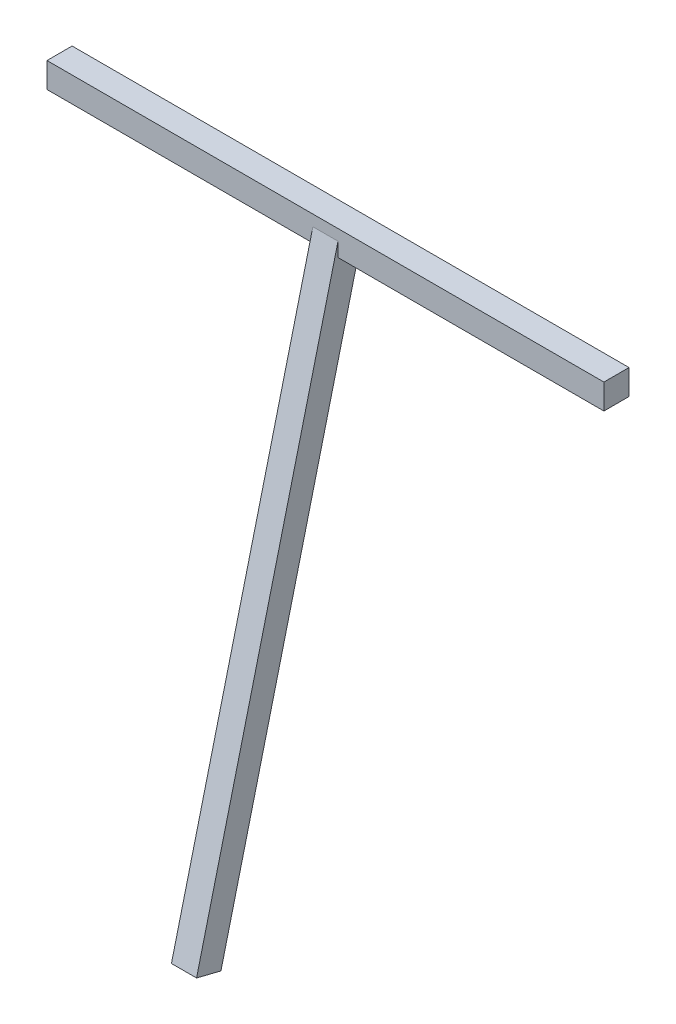
from build123d import *

# Parameters (mm, degrees)
BOSS_EXTRUDE1_DEPTH      = 332.5
BOSS_EXTRUDE1_DEPTH_BACK = 332.5
SKETCH1_W                = 30
SKETCH1_H                = 30
SKETCH2_W                = 30
SKETCH2_H                = 30
BOSS_EXTRUDE2_DEPTH      = 700


with BuildPart() as part:
    # Sketch1 → Boss-Extrude1 (new, two sides: drawn at the far end of the back side and taken through both)
    with BuildSketch(Plane(origin=(0, 0, 0), x_dir=(0, 0, -1), z_dir=(1, 0, 0)).offset(-BOSS_EXTRUDE1_DEPTH_BACK)):
        Rectangle(SKETCH1_W, SKETCH1_H)
    extrude(amount=BOSS_EXTRUDE1_DEPTH + BOSS_EXTRUDE1_DEPTH_BACK)

    # Sketch2 → Boss-Extrude2 (add)
    with BuildSketch(Plane(origin=(0, 0, 0), x_dir=(-1, 0, 0), z_dir=(0, -0.9702957262759964, 0.24192189559966812))):
        Rectangle(SKETCH2_W, SKETCH2_H)
    extrude(amount=BOSS_EXTRUDE2_DEPTH)


solid = part.part
